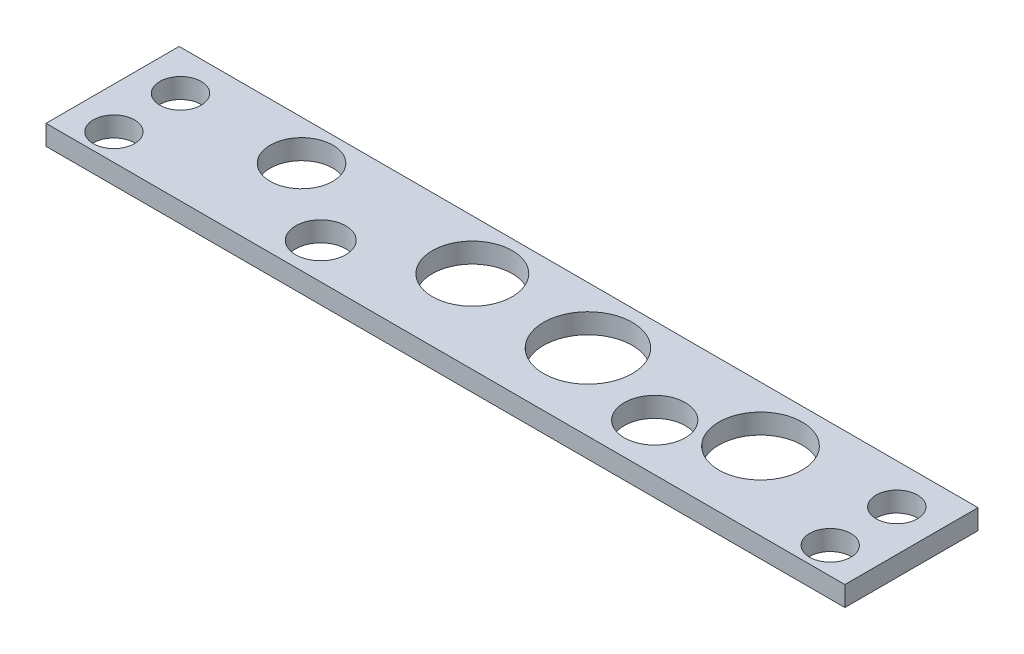
from build123d import *

# Parameters (mm, degrees)
SKETCH_1_R      = 3.127436884
SKETCH_1_R_2    = 2.290236854
SKETCH_1_R_3    = 3.334332824
SKETCH_1_R_4    = 3
SKETCH_1_R_5    = 1.883976709
SKETCH_1_R_6    = 2.353930843
SKETCH_1_R_7    = 1.55
EXTRUDE_1_DEPTH = 1.5


with BuildPart() as part:
    # 草图1 → 凸台-拉伸1 (new body)
    with BuildSketch(Plane(origin=(0, 0, 0), x_dir=(1, 0, 0), z_dir=(0, 1, 0))):
        Polygon((-30, 10), (-30, 0), (0, 0), (30, 0), (30, 10), align=None)
        with Locations((17.823374051, 5.840236854)):
            Circle(SKETCH_1_R, mode=Mode.SUBTRACT)
        with Locations((12.171443923, 3.55)):
            Circle(SKETCH_1_R_2, mode=Mode.SUBTRACT)
        with Locations((4.963185209, 5.738422027)):
            Circle(SKETCH_1_R_3, mode=Mode.SUBTRACT)
        with Locations((-4.210962245, 6.229894212)):
            Circle(SKETCH_1_R_4, mode=Mode.SUBTRACT)
        with Locations((-12.074517206, 2.707676886)):
            Circle(SKETCH_1_R_5, mode=Mode.SUBTRACT)
        with Locations((-17.808359365, 7)):
            Circle(SKETCH_1_R_6, mode=Mode.SUBTRACT)
        with Locations((-26.9, 2)):
            Circle(SKETCH_1_R_7, mode=Mode.SUBTRACT)
        with Locations((-26.9, 7)):
            Circle(SKETCH_1_R_7, mode=Mode.SUBTRACT)
        with Locations((26.9, 7)):
            Circle(SKETCH_1_R_7, mode=Mode.SUBTRACT)
        with Locations((26.9, 2)):
            Circle(SKETCH_1_R_7, mode=Mode.SUBTRACT)
    extrude(amount=EXTRUDE_1_DEPTH)


solid = part.part
